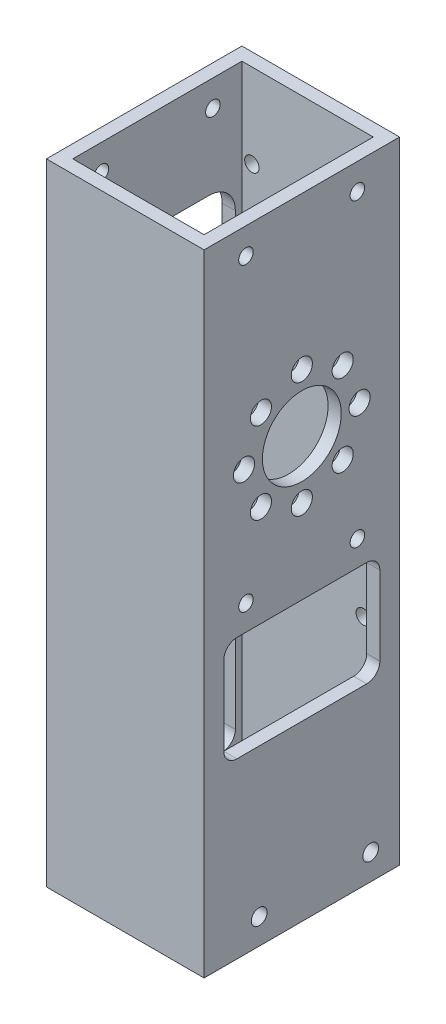
from build123d import *

# Parameters (mm, degrees)
SKETCH1_W               = 38.1
SKETCH1_H               = 47.244
SKETCH1_W_2             = 31.75
SKETCH1_H_2             = 40.894
BOSS_EXTRUDE1_DEPTH     = 152.4
SKETCH2_R               = 1.89865
CUT_EXTRUDE1_DEPTH      = 35.925
CUT_EXTRUDE1_DEPTH_BACK = 4.175
CUT_EXTRUDE3_DEPTH      = 3.175
CUT_EXTRUDE4_DEPTH      = 3.175
SKETCH6_R               = 9.525
SKETCH6_R_2             = 2.5527
CUT_EXTRUDE5_DEPTH      = 3.175
CUT_EXTRUDE6_DEPTH      = 3.175
F_6_32_TAPPED_HOLE1_D   = 3.5052
CUT_EXTRUDE10_REACH     = 49.244
SKETCH15_R              = 1.7526


with BuildPart() as part:
    # Sketch1 → Boss-Extrude1 (new body)
    with BuildSketch(Plane(origin=(0, 0, 0), x_dir=(1, 0, 0), z_dir=(0, 1, 0))):
        Rectangle(SKETCH1_W, SKETCH1_H)
        Rectangle(SKETCH1_W_2, SKETCH1_H_2, mode=Mode.SUBTRACT)
    extrude(amount=BOSS_EXTRUDE1_DEPTH)

    # Sketch2 → Cut-Extrude1 (cut, two sides)
    with BuildSketch(Plane.ZY.offset(-15.875)) as cut_extrude1_sk:
        with Locations((-16.645384182, 6.21538)):
            Circle(SKETCH2_R)
        with Locations((10.30030417, 6.18241423)):
            Circle(SKETCH2_R)
    extrude(amount=CUT_EXTRUDE1_DEPTH, mode=Mode.SUBTRACT)
    extrude(cut_extrude1_sk.sketch, amount=-CUT_EXTRUDE1_DEPTH_BACK, mode=Mode.SUBTRACT)

    # Sketch4 → Cut-Extrude3 (cut)
    with BuildSketch(Plane.ZY.offset(19.05)):
        with BuildLine():
            Line((15.6845, 10.16), (-15.6845, 10.16))
            ThreePointArc((-15.6845, 10.16), (-17.92956403, 11.08993597), (-18.8595, 13.335))
            Line((-18.8595, 13.335), (-18.8595, 64.135))
            ThreePointArc((-18.8595, 64.135), (-17.92956403, 66.38006403), (-15.6845, 67.31))
            Line((-15.6845, 67.31), (15.6845, 67.31))
            ThreePointArc((15.6845, 67.31), (17.92956403, 66.38006403), (18.8595, 64.135))
            Line((18.8595, 64.135), (18.8595, 13.335))
            ThreePointArc((18.8595, 13.335), (17.92956403, 11.08993597), (15.6845, 10.16))
        make_face()
    extrude(amount=-CUT_EXTRUDE3_DEPTH, mode=Mode.SUBTRACT)

    # Sketch5 → Cut-Extrude4 (cut)
    with BuildSketch(Plane(origin=(19.05, 0, 0), x_dir=(0, 0, -1), z_dir=(1, 0, 0))):
        with BuildLine():
            Line((15.6845, 67.31), (-15.6845, 67.31))
            ThreePointArc((-15.6845, 67.31), (-17.92956403, 66.38006403), (-18.8595, 64.135))
            Line((-18.8595, 64.135), (-18.8595, 45.085))
            ThreePointArc((-18.8595, 45.085), (-17.92956403, 42.83993597), (-15.6845, 41.91))
            Line((-15.6845, 41.91), (15.6845, 41.91))
            ThreePointArc((15.6845, 41.91), (17.92956403, 42.83993597), (18.8595, 45.085))
            Line((18.8595, 45.085), (18.8595, 64.135))
            ThreePointArc((18.8595, 64.135), (17.92956403, 66.38006403), (15.6845, 67.31))
        make_face()
    extrude(amount=-CUT_EXTRUDE4_DEPTH, mode=Mode.SUBTRACT)

    # Sketch6 → Cut-Extrude5 (cut)
    with BuildSketch(Plane.ZY.offset(-15.875)):
        with Locations((0, 101.6)):
            Circle(SKETCH6_R)
        with Locations((0, 87.63)):
            Circle(SKETCH6_R_2)
        with Locations((-9.878281733, 91.721718267)):
            Circle(SKETCH6_R_2)
        with Locations((-13.97, 101.6)):
            Circle(SKETCH6_R_2)
        with Locations((-9.878281733, 111.478281733)):
            Circle(SKETCH6_R_2)
        with Locations((0, 115.57)):
            Circle(SKETCH6_R_2)
        with Locations((9.878281733, 111.478281733)):
            Circle(SKETCH6_R_2)
        with Locations((13.97, 101.6)):
            Circle(SKETCH6_R_2)
        with Locations((9.878281733, 91.721718267)):
            Circle(SKETCH6_R_2)
    extrude(amount=-CUT_EXTRUDE5_DEPTH, mode=Mode.SUBTRACT)

    # Sketch7 → Cut-Extrude6 (cut)
    with BuildSketch(Plane.ZY.offset(19.05)):
        with BuildLine():
            Line((-12.5095, 77.47), (12.5095, 77.47))
            ThreePointArc((12.5095, 77.47), (16.999628061, 79.329871939), (18.8595, 83.82))
            Line((18.8595, 83.82), (18.8595, 121.92))
            ThreePointArc((18.8595, 121.92), (16.999628061, 126.410128061), (12.5095, 128.27))
            Line((12.5095, 128.27), (-12.5095, 128.27))
            ThreePointArc((-12.5095, 128.27), (-16.999628061, 126.410128061), (-18.8595, 121.92))
            Line((-18.8595, 121.92), (-18.8595, 83.82))
            ThreePointArc((-18.8595, 83.82), (-16.999628061, 79.329871939), (-12.5095, 77.47))
        make_face()
    extrude(amount=-CUT_EXTRUDE6_DEPTH, mode=Mode.SUBTRACT)

    # #6-32 Tapped Hole1 (through all)
    with Locations(Plane(origin=(19.05, 73.406, -13.423592181), x_dir=(0, 0, 1), z_dir=(1, 0, 0))):
        with Locations((0, 0), (26.924, 0), (26.924, -72.644), (0, -72.644)):
            Hole(F_6_32_TAPPED_HOLE1_D / 2)

    # Sketch15 → Cut-Extrude10 (cut, up to next)
    with BuildSketch(Plane(origin=(0, 0, -23.622), x_dir=(-1, 0, 0), z_dir=(0, 0, -1)), mode=Mode.PRIVATE) as cut_extrude10_sk1:
        with Locations((-13.462, 50.8)):
            Circle(SKETCH15_R)
    cut_extrude10_tool1 = extrude(cut_extrude10_sk1.sketch, amount=-CUT_EXTRUDE10_REACH, mode=Mode.PRIVATE) & part.part
    add(cut_extrude10_tool1.solids().sort_by_distance((13.462, 50.8, -23.622))[0], mode=Mode.SUBTRACT)
    # Sketch15 → Cut-Extrude10 (cut, up to next)
    with BuildSketch(Plane(origin=(0, 0, -23.622), x_dir=(-1, 0, 0), z_dir=(0, 0, -1)), mode=Mode.PRIVATE) as cut_extrude10_sk2:
        with Locations((13.462, 50.8)):
            Circle(SKETCH15_R)
    cut_extrude10_tool2 = extrude(cut_extrude10_sk2.sketch, amount=-CUT_EXTRUDE10_REACH, mode=Mode.PRIVATE) & part.part
    add(cut_extrude10_tool2.solids().sort_by_distance((-13.462, 50.8, -23.622))[0], mode=Mode.SUBTRACT)
    # Sketch15 → Cut-Extrude10 (cut, up to next)
    with BuildSketch(Plane(origin=(0, 0, -23.622), x_dir=(-1, 0, 0), z_dir=(0, 0, -1)), mode=Mode.PRIVATE) as cut_extrude10_sk3:
        with Locations((-13.462, 76.2)):
            Circle(SKETCH15_R)
    cut_extrude10_tool3 = extrude(cut_extrude10_sk3.sketch, amount=-CUT_EXTRUDE10_REACH, mode=Mode.PRIVATE) & part.part
    add(cut_extrude10_tool3.solids().sort_by_distance((13.462, 76.2, -23.622))[0], mode=Mode.SUBTRACT)
    # Sketch15 → Cut-Extrude10 (cut, up to next)
    with BuildSketch(Plane(origin=(0, 0, -23.622), x_dir=(-1, 0, 0), z_dir=(0, 0, -1)), mode=Mode.PRIVATE) as cut_extrude10_sk4:
        with Locations((13.462, 76.2)):
            Circle(SKETCH15_R)
    cut_extrude10_tool4 = extrude(cut_extrude10_sk4.sketch, amount=-CUT_EXTRUDE10_REACH, mode=Mode.PRIVATE) & part.part
    add(cut_extrude10_tool4.solids().sort_by_distance((-13.462, 76.2, -23.622))[0], mode=Mode.SUBTRACT)
    # Sketch15 → Cut-Extrude10 (cut, up to next)
    with BuildSketch(Plane(origin=(0, 0, -23.622), x_dir=(-1, 0, 0), z_dir=(0, 0, -1)), mode=Mode.PRIVATE) as cut_extrude10_sk5:
        with Locations((-13.462, 132.08)):
            Circle(SKETCH15_R)
    cut_extrude10_tool5 = extrude(cut_extrude10_sk5.sketch, amount=-CUT_EXTRUDE10_REACH, mode=Mode.PRIVATE) & part.part
    add(cut_extrude10_tool5.solids().sort_by_distance((13.462, 132.08, -23.622))[0], mode=Mode.SUBTRACT)
    # Sketch15 → Cut-Extrude10 (cut, up to next)
    with BuildSketch(Plane(origin=(0, 0, -23.622), x_dir=(-1, 0, 0), z_dir=(0, 0, -1)), mode=Mode.PRIVATE) as cut_extrude10_sk6:
        with Locations((13.462, 132.08)):
            Circle(SKETCH15_R)
    cut_extrude10_tool6 = extrude(cut_extrude10_sk6.sketch, amount=-CUT_EXTRUDE10_REACH, mode=Mode.PRIVATE) & part.part
    add(cut_extrude10_tool6.solids().sort_by_distance((-13.462, 132.08, -23.622))[0], mode=Mode.SUBTRACT)


solid = part.part
